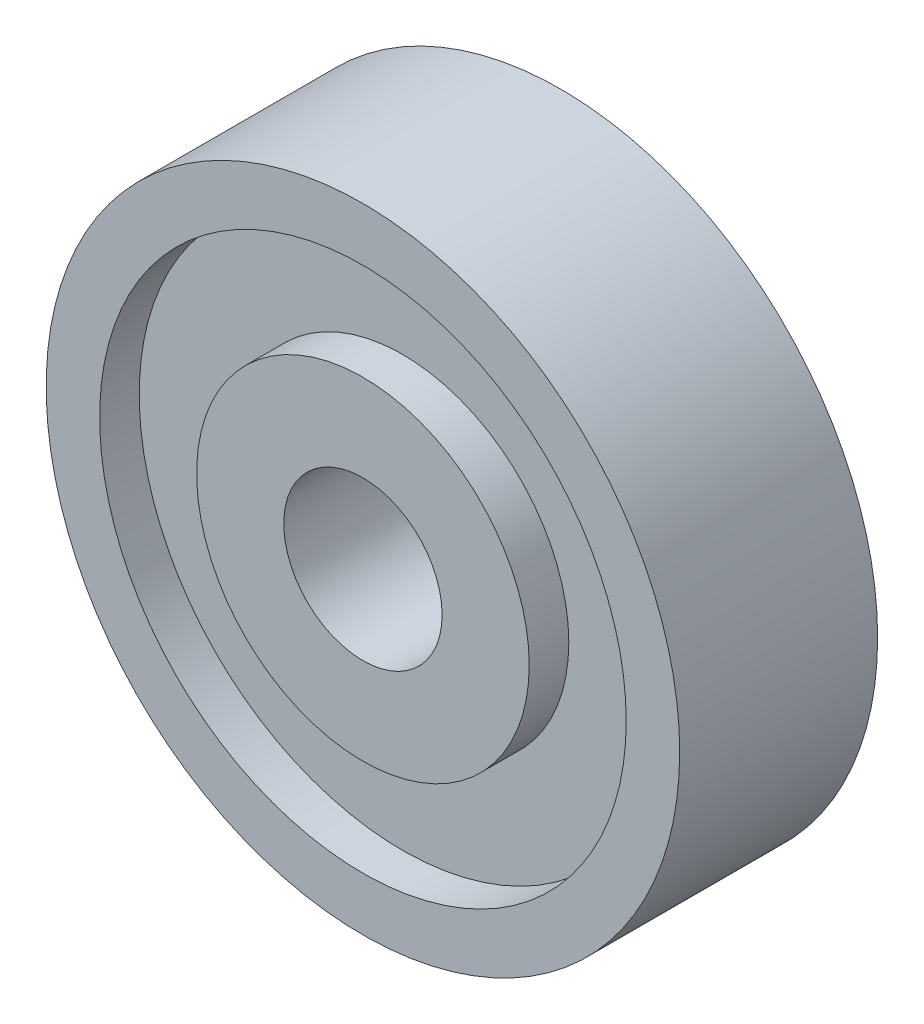
from build123d import *

# Parameters (mm, degrees)
SKETCH1_R          = 8
SKETCH1_R_2        = 2
EXTRUDE1_DEPTH     = 5
SKETCH2_R          = 6.65
SKETCH2_R_2        = 4.2
CUT_EXTRUDE1_DEPTH = 1


with BuildPart() as part:
    # Sketch1 → Extrude1 (new body)
    with BuildSketch(Plane.XY):
        Circle(SKETCH1_R)
        Circle(SKETCH1_R_2, mode=Mode.SUBTRACT)
    extrude(amount=EXTRUDE1_DEPTH)

    # Sketch2 → Cut-Extrude1 (cut)
    with BuildSketch(Plane.XY.offset(5)):
        Circle(SKETCH2_R)
        Circle(SKETCH2_R_2, mode=Mode.SUBTRACT)
    cut_extrude1 = extrude(amount=-CUT_EXTRUDE1_DEPTH, mode=Mode.SUBTRACT)

    # Mirror1: Cut-Extrude1 across plane
    add(cut_extrude1.mirror(Plane(origin=(0, 0, 2.5), x_dir=(1, 0, 0), z_dir=(0, 0, -1))), mode=Mode.SUBTRACT)


solid = part.part
